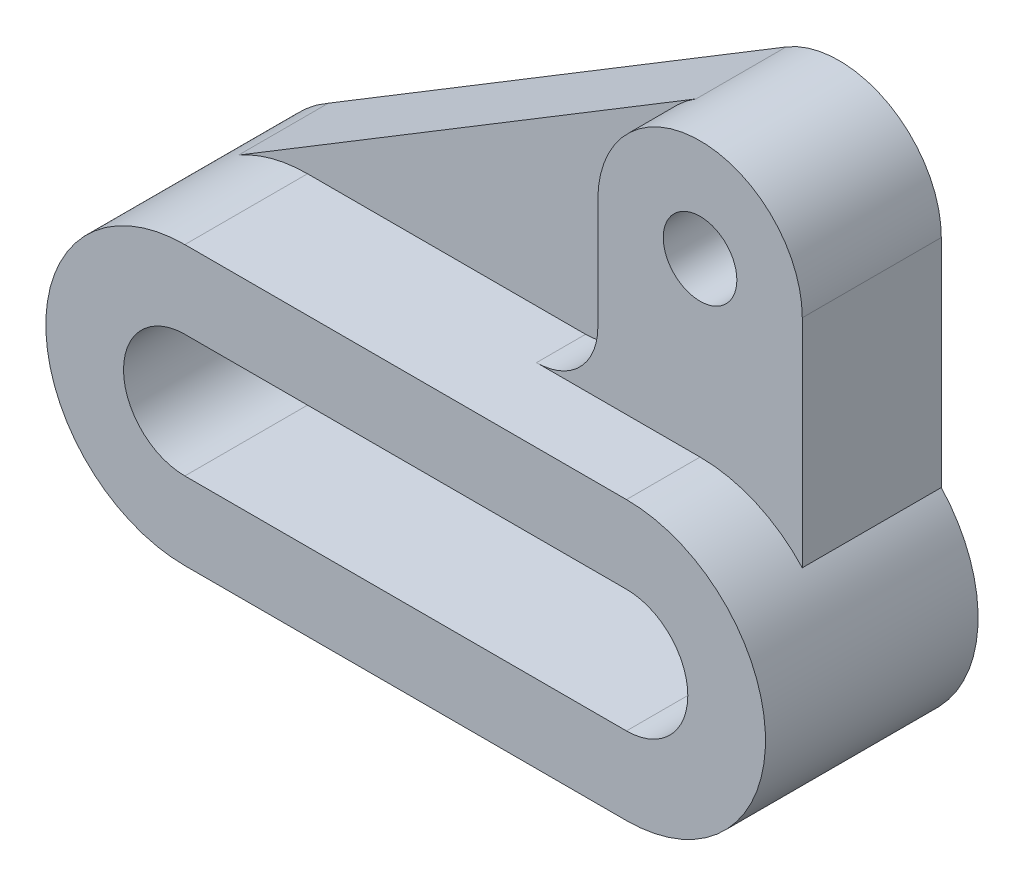
from build123d import *

# Parameters (mm, degrees)
EXTRUDE_1_DEPTH = 52
SKETCH_2_R      = 9
EXTRUDE_2_DEPTH = 34
EXTRUDE_3_DEPTH = 22


with BuildPart() as part:
    # 스케치1 → 보스-돌출1 (new body)
    with BuildSketch(Plane.XY):
        with BuildLine():
            Line((0, 34), (108, 34))
            ThreePointArc((108, 34), (142, 0), (108, -34))
            Line((108, -34), (0, -34))
            ThreePointArc((0, -34), (-34, 0), (0, 34))
        make_face()
        with BuildLine():
            Line((0, 15), (108, 15))
            ThreePointArc((108, 15), (123, 0), (108, -15))
            Line((108, -15), (0, -15))
            ThreePointArc((0, -15), (-15, 0), (0, 15))
        make_face(mode=Mode.SUBTRACT)
    extrude(amount=EXTRUDE_1_DEPTH)

    # 스케치2 → 보스-돌출2 (add)
    with BuildSketch(Plane.XY):
        with BuildLine():
            Line((108, 34), (68, 34))
            ThreePointArc((68, 34), (78.606601718, 38.393398282), (83, 49))
            Line((83, 49), (83, 76))
            ThreePointArc((83, 76), (108, 101), (133, 76))
            Line((133, 76), (133, 23.043437244))
            ThreePointArc((133, 23.043437244), (121.647767834, 31.140623519), (108, 34))
        make_face()
        with Locations((108, 76)):
            Circle(SKETCH_2_R, mode=Mode.SUBTRACT)
    extrude(amount=EXTRUDE_2_DEPTH)

    # 스케치3 → 보스-돌출3 (add)
    with BuildSketch(Plane.XY):
        with BuildLine():
            Line((-16.891194038, 29.507415407), (95.037714778, 97.377070936))
            ThreePointArc((95.037714778, 97.377070936), (86.216323421, 88.266679857), (83, 76))
            Line((83, 76), (83, 49))
            ThreePointArc((83, 49), (78.606601718, 38.393398282), (68, 34))
            Line((68, 34), (0, 34))
            ThreePointArc((0, 34), (-8.739218391, 32.857663671), (-16.891194038, 29.507415407))
        make_face()
    extrude(amount=EXTRUDE_3_DEPTH)


solid = part.part
